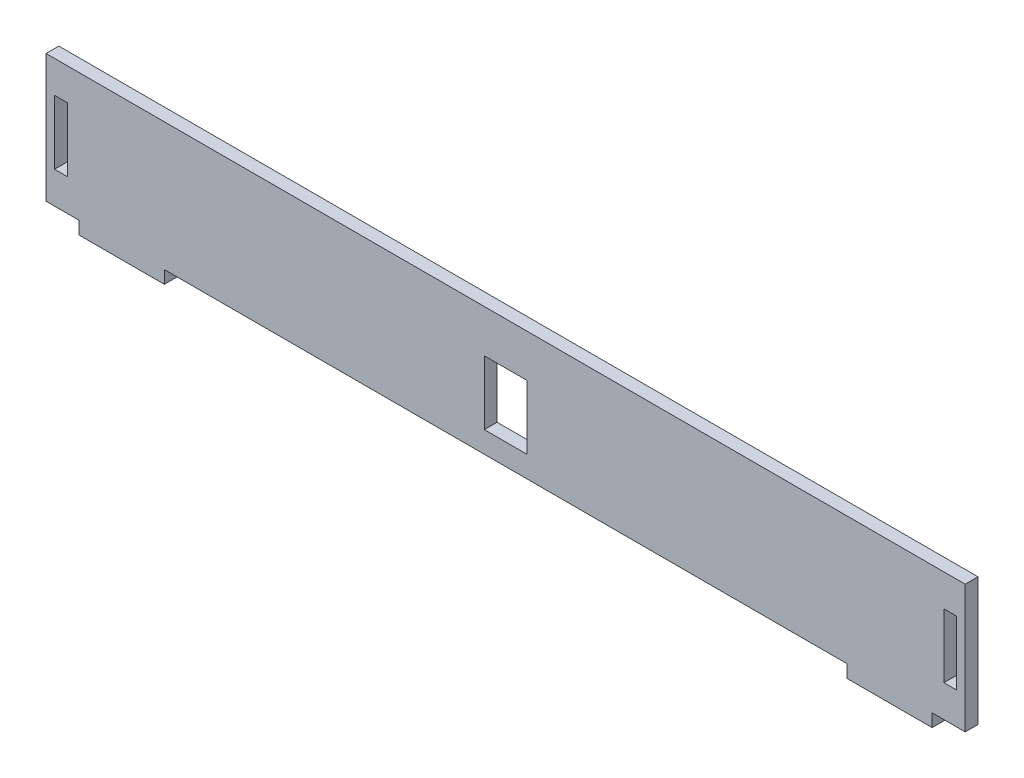
from build123d import *

# Parameters (mm, degrees)
SKETCH_1_W      = 3
SKETCH_1_H      = 15
EXTRUDE_1_DEPTH = 3


with BuildPart() as part:
    # 草图1 → 凸台-拉伸1 (new body)
    with BuildSketch(Plane.XY):
        Polygon((20, 0), (180, 0), (180, -3), (200, -3), (200, 0), (202.75, 0), (207.75, 0), (207.75, 30), (202.75, 30), (200, 30), (0, 30), (-2.75, 30), (-7.75, 30), (-7.75, 0), (-2.75, 0), (0, 0), (0, -3), (20, -3), align=None)
        with Locations((204.25, 15)):
            Rectangle(SKETCH_1_W, SKETCH_1_H, mode=Mode.SUBTRACT)
        with Locations((-4.25, 15)):
            Rectangle(SKETCH_1_W, SKETCH_1_H, mode=Mode.SUBTRACT)
        Polygon((100, 5), (105, 5), (105, 20), (95, 20), (95, 5), align=None, mode=Mode.SUBTRACT)
    extrude(amount=EXTRUDE_1_DEPTH)


solid = part.part
